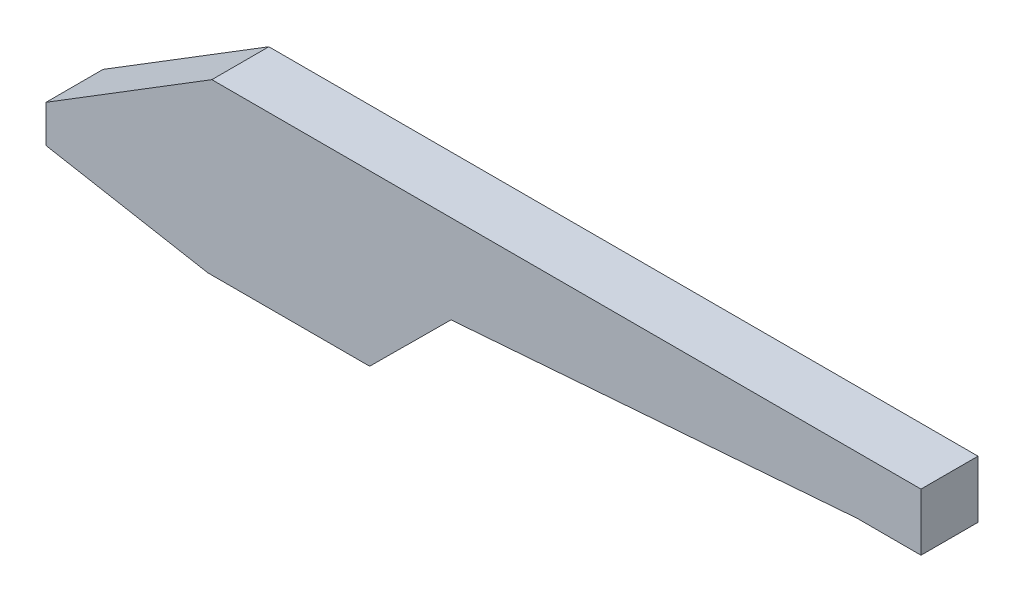
from build123d import *

# Parameters (mm, degrees)
BOSS_EXTRUDE1_DEPTH = 40


with BuildPart() as part:
    # Sketch1 → Boss-Extrude1 (new body, symmetric)
    with BuildSketch(Plane.XY):
        Polygon((576.530281573, 118.813515451), (-381.24605126, 118.813515451), (-614.016581357, -25.106107257), (-614.016581357, -77.668223147), (-386.909457622, -118.813515451), (-159.802333887, -118.813515451), (-45.574406616, -5.335493482), (524.577232755, 38.483934534), (614.016581357, 38.369843561), (614.016581357, 118.813515451), align=None)
    extrude(amount=BOSS_EXTRUDE1_DEPTH, both=True)


solid = part.part
